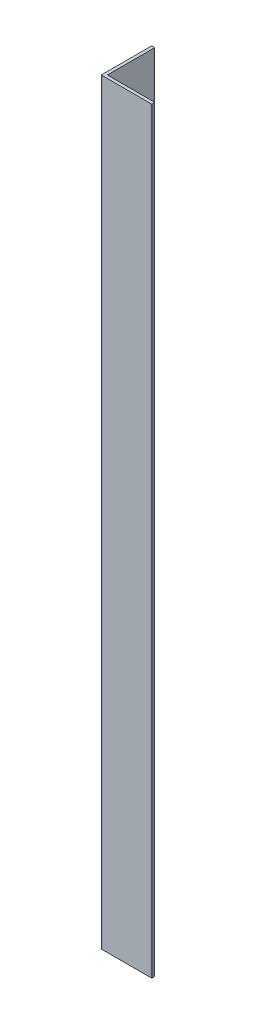
from build123d import *

# Parameters (mm, degrees)
EXTRUDE_1_DEPTH = 300


with BuildPart() as part:
    # уголок-20х20 → Бобышка-Вытянуть1 (new body)
    with BuildSketch(Plane(origin=(0, 0, 0), x_dir=(1, 0, 0), z_dir=(0, 1, 0))):
        with BuildLine():
            Line((-10.917874396, 0.2), (-10.917874396, 19.8))
            ThreePointArc((-10.917874396, 19.8), (-10.859295752, 19.941421356), (-10.717874396, 20))
            Line((-10.717874396, 20), (-9.917874396, 20))
            ThreePointArc((-9.917874396, 20), (-9.77645304, 19.941421356), (-9.717874396, 19.8))
            Line((-9.717874396, 19.8), (-9.717874396, 1.4))
            ThreePointArc((-9.717874396, 1.4), (-9.659295752, 1.258578644), (-9.517874396, 1.2))
            Line((-9.517874396, 1.2), (8.882125604, 1.2))
            ThreePointArc((8.882125604, 1.2), (9.02354696, 1.141421356), (9.082125604, 1))
            Line((9.082125604, 1), (9.082125604, 0.2))
            ThreePointArc((9.082125604, 0.2), (9.02354696, 0.058578644), (8.882125604, 0))
            Line((8.882125604, 0), (-10.717874396, 0))
            ThreePointArc((-10.717874396, 0), (-10.859295752, 0.058578644), (-10.917874396, 0.2))
        make_face()
    extrude(amount=EXTRUDE_1_DEPTH)


solid = part.part
